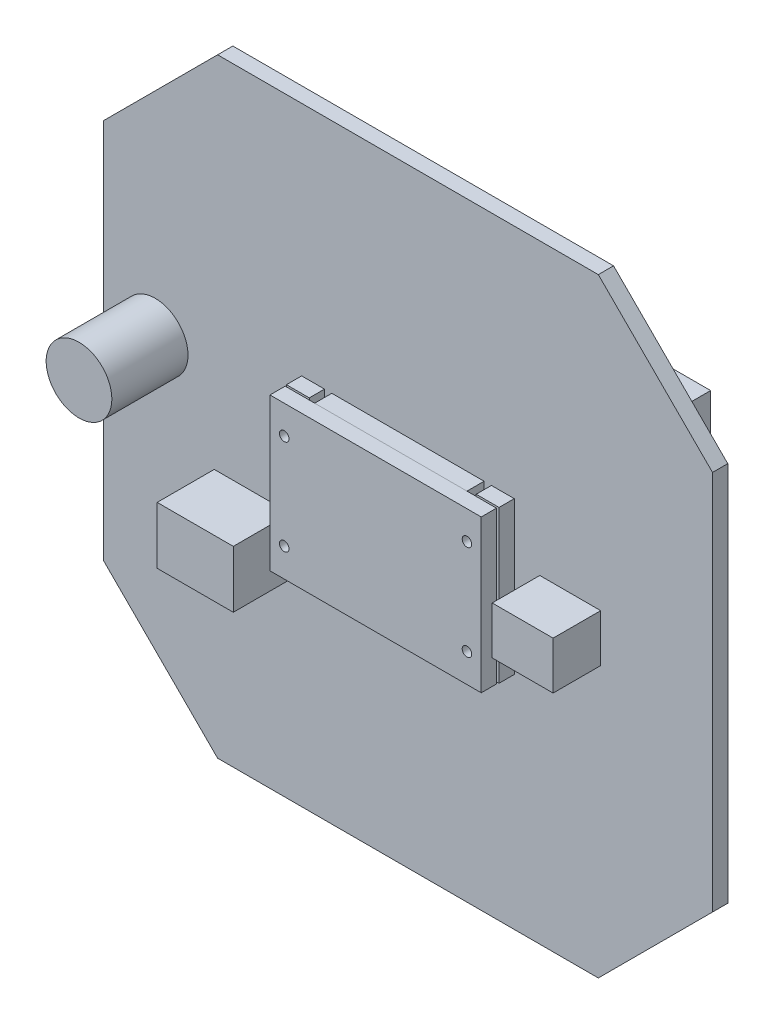
from build123d import *

# Parameters (mm, degrees)
BOSS_EXTRUDE1_DEPTH  = 0.8
SKETCH2_W            = 17
SKETCH2_H            = 3
BOSS_EXTRUDE2_DEPTH  = 1.5
SKETCH3_W            = 8
SKETCH3_H            = 8
BOSS_EXTRUDE3_DEPTH  = 0.9
CIRPATTERN2_COUNT    = 4
SKETCH5_W            = 1.2
SKETCH5_H            = 8
BOSS_EXTRUDE4_DEPTH  = 0.8
SKETCH6_W            = 11.1
SKETCH6_H            = 8
BOSS_EXTRUDE5_DEPTH  = 0.8
SKETCH10_W           = 3.2
SKETCH10_H           = 2.5
BOSS_EXTRUDE7_DEPTH  = 2.5
SKETCH11_W           = 4
SKETCH11_H           = 3
BOSS_EXTRUDE8_DEPTH  = 3
SKETCH12_R           = 1.725
BOSS_EXTRUDE10_DEPTH = 4
SKETCH14_R           = 0.25
CUT_EXTRUDE1_DEPTH   = 0.8


with BuildPart() as part:
    # Sketch1 → Boss-Extrude1 (new body)
    with BuildSketch(Plane.XY):
        Polygon((-10, 16), (-16, 10), (-16, -10), (-10, -16), (10, -16), (16, -10), (16, 10), (10, 16), align=None)
    extrude(amount=BOSS_EXTRUDE1_DEPTH)

    # Sketch2 → Boss-Extrude2 (add)
    with BuildSketch(Plane(origin=(0, 0, 0), x_dir=(-1, 0, 0), z_dir=(0, 0, -1))):
        with Locations((-3.275675651, -12.5)):
            Rectangle(SKETCH2_W, SKETCH2_H)
    boss_extrude2 = extrude(amount=BOSS_EXTRUDE2_DEPTH)

    # Sketch3 → Boss-Extrude3 (add)
    with BuildSketch(Plane.XY.offset(0.8)):
        with Locations((0, -0.4)):
            Rectangle(SKETCH3_W, SKETCH3_H)
    extrude(amount=BOSS_EXTRUDE3_DEPTH)

    # CirPattern2: Boss-Extrude2 ×4 about axis
    cirpattern2_axis = Axis((0, -0.4, 0), (0, 0, 1))
    for i in range(1, CIRPATTERN2_COUNT):
        add(boss_extrude2.rotate(cirpattern2_axis, i * 360 / CIRPATTERN2_COUNT))

    # Sketch5 → Boss-Extrude4 (add)
    with BuildSketch(Plane.XY.offset(0.8)):
        with Locations((4.983974318, -0.4)):
            Rectangle(SKETCH5_W, SKETCH5_H)
    boss_extrude4 = extrude(amount=BOSS_EXTRUDE4_DEPTH)

    # Mirror1: Boss-Extrude4 across plane
    add(boss_extrude4.mirror(Plane(origin=(0, 0, 0), x_dir=(0, 0, 1), z_dir=(1, 0, 0))))

    # Sketch10 → Boss-Extrude7 (add)
    with BuildSketch(Plane.XY.offset(0.8)):
        with Locations((8.525, -0.475)):
            Rectangle(SKETCH10_W, SKETCH10_H)
    extrude(amount=BOSS_EXTRUDE7_DEPTH)

    # Sketch11 → Boss-Extrude8 (add)
    with BuildSketch(Plane.XY.offset(0.8)):
        with Locations((-8.175, -4.45)):
            Rectangle(SKETCH11_W, SKETCH11_H)
    extrude(amount=BOSS_EXTRUDE8_DEPTH)

    # Sketch12 → Boss-Extrude10 (add)
    with BuildSketch(Plane.XY.offset(0.8)):
        with Locations((-13.28, 1.56)):
            Circle(SKETCH12_R)
    extrude(amount=BOSS_EXTRUDE10_DEPTH)


with BuildPart() as body_2:
    # Sketch6 → Boss-Extrude5 (new body)
    with BuildSketch(Plane.XY.offset(1.7)):
        with Locations((0, -0.4)):
            Rectangle(SKETCH6_W, SKETCH6_H)
    extrude(amount=BOSS_EXTRUDE5_DEPTH)

    # Sketch14 → Cut-Extrude1 (cut)
    with BuildSketch(Plane.XY.offset(2.5)):
        with Locations((-4.8, 2.1)):
            Circle(SKETCH14_R)
        with Locations((-4.8, -2.9)):
            Circle(SKETCH14_R)
    cut_extrude1 = extrude(amount=-CUT_EXTRUDE1_DEPTH, mode=Mode.SUBTRACT)

    # Mirror2: Cut-Extrude1 across plane
    add(cut_extrude1.mirror(Plane(origin=(0, 0, 0), x_dir=(0, 0, 1), z_dir=(1, 0, 0))), mode=Mode.SUBTRACT)


solid = Compound([part.part, body_2.part])
